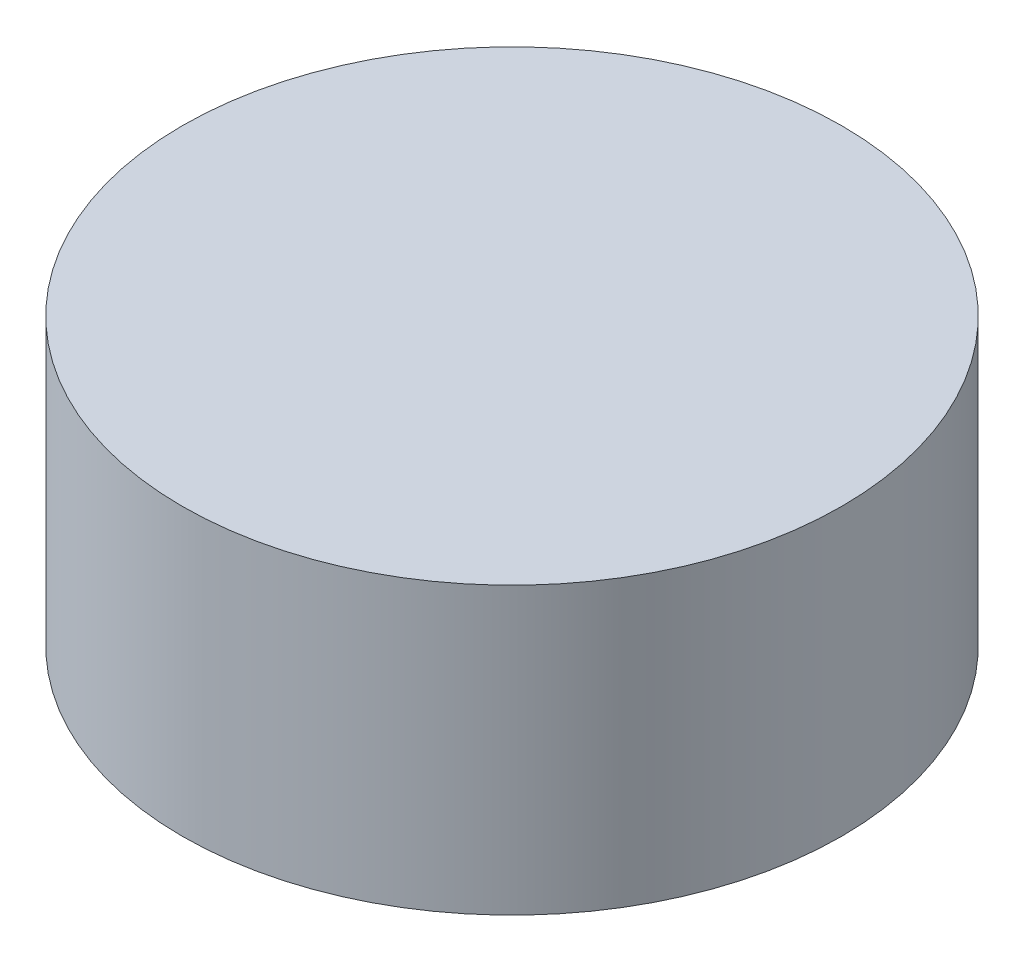
from build123d import *

# Parameters (mm, degrees)
SKETCH2_R           = 1500
BOSS_EXTRUDE1_DEPTH = 1300
SHELL4_T            = -100


with BuildPart() as part:
    # Sketch2 → Boss-Extrude1 (new body)
    with BuildSketch(Plane(origin=(0, 0, 0), x_dir=(1, 0, 0), z_dir=(0, 1, 0))):
        with Locations(Location((0, 0, 0), (0, 0, 270))):
            Circle(SKETCH2_R)
    extrude(amount=BOSS_EXTRUDE1_DEPTH)

    # Shell4
    shell4_openings = [part.faces().sort_by_distance(p)[0] for p in [
        (0, 0, 0),
    ]]
    offset(amount=SHELL4_T, openings=shell4_openings, kind=Kind.INTERSECTION)


solid = part.part
